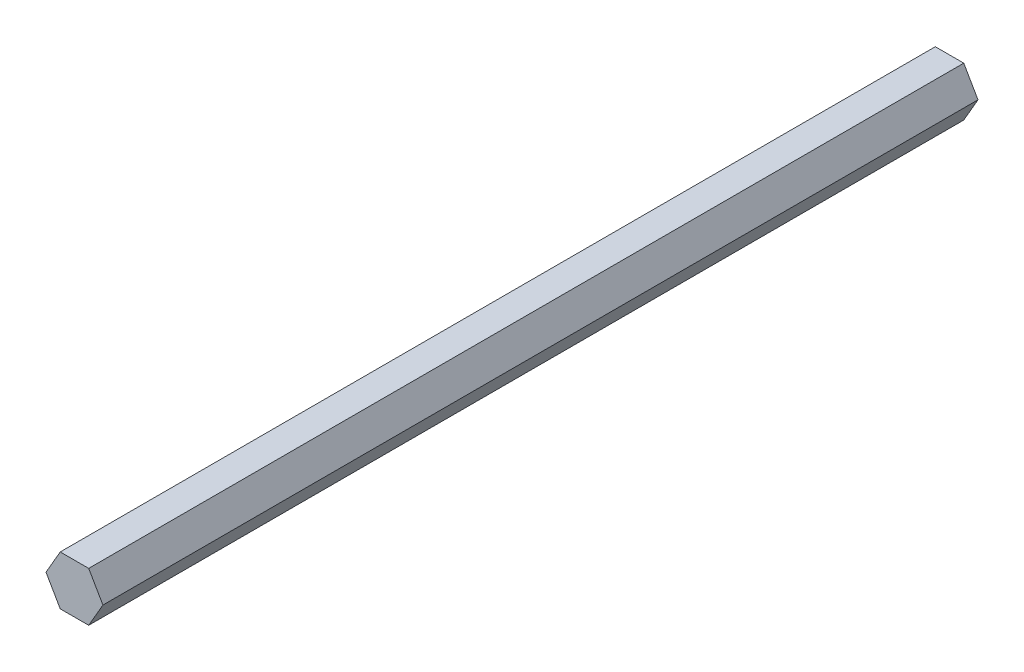
from build123d import *

# Parameters (mm, degrees)
BOSS_EXTRUDE1_DEPTH = 225.425


with BuildPart() as part:
    # Sketch1 → Boss-Extrude1 (new body)
    with BuildSketch(Plane.XY):
        Polygon((-7.332348419, 0), (-3.666174209, -6.35), (3.666174209, -6.35), (7.332348419, 0), (3.666174209, 6.35), (-3.666174209, 6.35), align=None)
    extrude(amount=BOSS_EXTRUDE1_DEPTH)


solid = part.part
